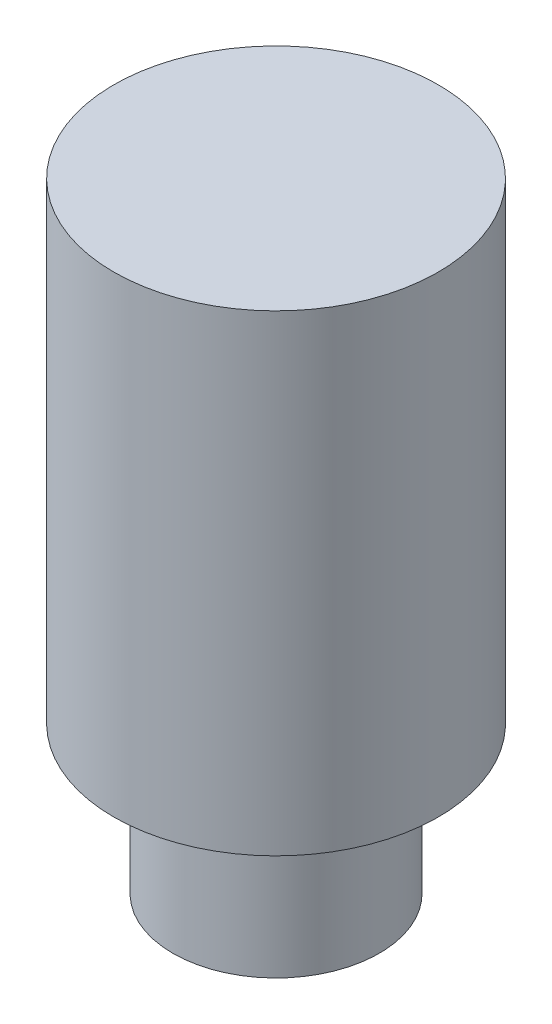
from build123d import *

# Parameters (mm, degrees)
SKETCH1_R           = 3.5
BOSS_EXTRUDE1_DEPTH = 5
SKETCH2_R           = 5.5
BOSS_EXTRUDE2_DEPTH = 16
SCALE1_SCALE        = 0.225


with BuildPart() as part:
    # Sketch1 → Boss-Extrude1 (new body)
    with BuildSketch(Plane(origin=(0, 0, 0), x_dir=(1, 0, 0), z_dir=(0, 1, 0))):
        Circle(SKETCH1_R)
    extrude(amount=BOSS_EXTRUDE1_DEPTH)

    # Sketch2 → Boss-Extrude2 (add)
    with BuildSketch(Plane(origin=(0, 5, 0), x_dir=(1, 0, 0), z_dir=(0, 1, 0))):
        Circle(SKETCH2_R)
    extrude(amount=BOSS_EXTRUDE2_DEPTH)


with BuildPart() as part_1:
    # Scale1: scaled about (0, 11.820495186, 0)
    add(part.part.scale(SCALE1_SCALE).moved(Location((0, 9.160883769, 0))))


solid = part_1.part
